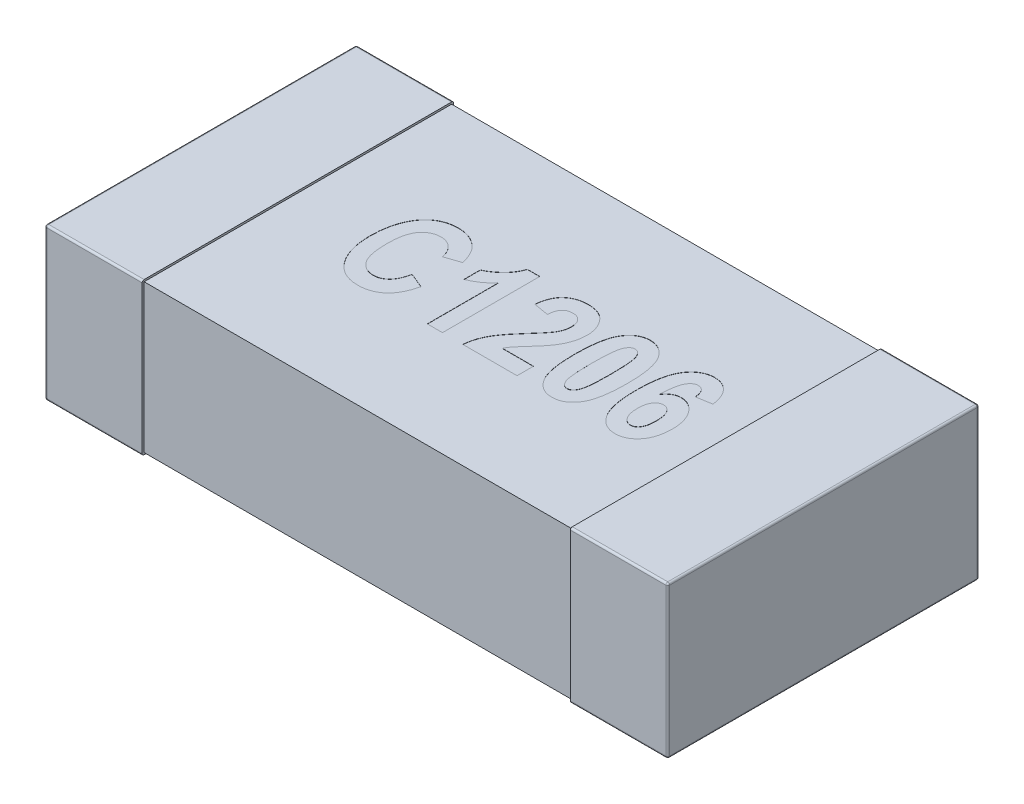
from build123d import *

# Parameters (mm, degrees)
SKETCH1_W            = 0.5
SKETCH1_H            = 1.6
THICKNESS_DEPTH      = 0.78
FILLET1_R            = 0.01
SKETCH2_W            = 1.58
SKETCH2_H            = 0.76
BOSS_EXTRUDE2_DEPTH  = 1.1
FILLET1_OF_MIRROR3_R = 0.01
CUT_EXTRUDE1_DEPTH   = 0.001


with BuildPart() as part:
    # Sketch1 → THICKNESS (new body)
    with BuildSketch(Plane(origin=(0, 0, 0), x_dir=(1, 0, 0), z_dir=(0, 1, 0))):
        with Locations((-1.35, 0)):
            Rectangle(SKETCH1_W, SKETCH1_H)
    thickness = extrude(amount=THICKNESS_DEPTH)

    # Fillet1
    fillet1_edges = [part.edges().sort_by_distance(p)[0] for p in [
        (-1.35, 0.78, -0.8),
        (-1.6, 0.78, 0),
        (-1.35, 0, -0.8),
        (-1.35, 0, 0.8),
        (-1.6, 0, 0),
        (-1.35, 0.78, 0.8),
        (-1.6, 0.39, -0.8),
        (-1.6, 0.39, 0.8),
    ]]
    fillet(fillet1_edges, radius=FILLET1_R)

    # Sketch2 → Boss-Extrude2 (add)
    with BuildSketch(Plane(origin=(0, 0, 0), x_dir=(0, 0, -1), z_dir=(1, 0, 0))):
        with Locations((0, 0.39)):
            Rectangle(SKETCH2_W, SKETCH2_H)
    boss_extrude2 = extrude(amount=-BOSS_EXTRUDE2_DEPTH)

    # Mirror3: THICKNESS, Boss-Extrude2 across plane
    add(thickness.mirror(Plane(origin=(0, 0, 0), x_dir=(0, 0, 1), z_dir=(1, 0, 0))))
    add(boss_extrude2.mirror(Plane(origin=(0, 0, 0), x_dir=(0, 0, 1), z_dir=(1, 0, 0))))

    # Fillet1 of Mirror3
    fillet1_of_mirror3_edges = [part.edges().sort_by_distance(p)[0] for p in [
        (1.35, 0.78, -0.8),
        (1.6, 0.78, 0),
        (1.35, 0, -0.8),
        (1.35, 0, 0.8),
        (1.6, 0, 0),
        (1.35, 0.78, 0.8),
        (1.6, 0.39, -0.8),
        (1.6, 0.39, 0.8),
    ]]
    fillet(fillet1_of_mirror3_edges, radius=FILLET1_OF_MIRROR3_R)

    # Sketch3 → Cut-Extrude1 (cut)
    with BuildSketch(Plane(origin=(0, 0.77, 0), x_dir=(1, 0, 0), z_dir=(0, 1, 0))):
        with BuildLine():
            Line((-0.444805195, -0.068181818), (-0.366883117, -0.100649351))
            add(Edge.make_bspline(
                [(-0.366883117, -0.100649351), (-0.36849243, -0.107199419), (-0.371628256, -0.119962551), (-0.377560807, -0.138204654), (-0.384088901, -0.155130547), (-0.391557408, -0.17064549), (-0.399710269, -0.1848856), (-0.40876644, -0.19771075), (-0.418555537, -0.209186605), (-0.429133236, -0.219286352), (-0.440482385, -0.227976376), (-0.452284327, -0.23572007), (-0.464843824, -0.24206825), (-0.477985009, -0.247428311), (-0.491811195, -0.251412625), (-0.506217336, -0.254410987), (-0.521265264, -0.256126789), (-0.531516362, -0.256369892), (-0.536728896, -0.256493506)],
                knots=[0, 0, 0, 0, 2.0228e-05, 3.9416e-05, 5.7504e-05, 7.4612e-05, 9.1023e-05, 0.000106675, 0.000121641, 0.00013621, 0.000150457, 0.000164472, 0.000178493, 0.000192605, 0.000206988, 0.000221594, 0.000236709, 0.000252346, 0.000252346, 0.000252346, 0.000252346], degree=3))
            add(Edge.make_bspline(
                [(-0.536728896, -0.256493506), (-0.543269039, -0.256346468), (-0.556081026, -0.256058423), (-0.574776176, -0.252959131), (-0.592566222, -0.248250296), (-0.609419096, -0.24148838), (-0.625354781, -0.232845212), (-0.640204933, -0.222139378), (-0.654316065, -0.209769439), (-0.662520716, -0.200124533), (-0.666700487, -0.195211039)],
                knots=[0, 0, 0, 0, 1.9603e-05, 3.8402e-05, 5.6689e-05, 7.472e-05, 9.2745e-05, 0.000110932, 0.000129545, 0.000148874, 0.000148874, 0.000148874, 0.000148874], degree=3))
            add(Edge.make_bspline(
                [(-0.666700487, -0.195211039), (-0.671294895, -0.189144714), (-0.680550756, -0.176923542), (-0.692170974, -0.156770852), (-0.702054193, -0.135120172), (-0.710143121, -0.111951881), (-0.716448013, -0.08724031), (-0.720855952, -0.060973678), (-0.723503053, -0.033164691), (-0.723849024, -0.014109002), (-0.724025974, -0.004362825)],
                knots=[0, 0, 0, 0, 2.2811e-05, 4.5956e-05, 6.961e-05, 9.4126e-05, 0.000119472, 0.000146027, 0.000173952, 0.000203187, 0.000203187, 0.000203187, 0.000203187], degree=3))
            add(Edge.make_bspline(
                [(-0.724025974, -0.004362825), (-0.723864318, 0.005925643), (-0.723549438, 0.025965852), (-0.720714427, 0.055142491), (-0.716392573, 0.082649117), (-0.709948869, 0.108383494), (-0.70187671, 0.132493389), (-0.691903581, 0.154828456), (-0.680323777, 0.175622287), (-0.67087598, 0.188041064), (-0.666193182, 0.194196429)],
                knots=[0, 0, 0, 0, 3.0858e-05, 6.0106e-05, 8.7861e-05, 0.000114315, 0.000139598, 0.000164034, 0.000187618, 0.000210795, 0.000210795, 0.000210795, 0.000210795], degree=3))
            add(Edge.make_bspline(
                [(-0.666193182, 0.194196429), (-0.661941432, 0.19917207), (-0.653562146, 0.208977992), (-0.639239952, 0.221675972), (-0.62385342, 0.232469708), (-0.607408116, 0.241307035), (-0.589830453, 0.24818042), (-0.571206463, 0.253030388), (-0.551461576, 0.255892063), (-0.53795592, 0.256289961), (-0.531047078, 0.256493506)],
                knots=[0, 0, 0, 0, 1.9616e-05, 3.8658e-05, 5.7235e-05, 7.5892e-05, 9.4527e-05, 0.000113722, 0.000133509, 0.000154232, 0.000154232, 0.000154232, 0.000154232], degree=3))
            add(Edge.make_bspline(
                [(-0.531047078, 0.256493506), (-0.525393125, 0.256358172), (-0.514280545, 0.256092177), (-0.497985961, 0.253965699), (-0.482461365, 0.250226584), (-0.467555212, 0.245322032), (-0.453398282, 0.238759793), (-0.439949639, 0.230796898), (-0.427156396, 0.221459527), (-0.41940221, 0.214200592), (-0.415482955, 0.210531656)],
                knots=[0, 0, 0, 0, 1.6959e-05, 3.3332e-05, 4.9181e-05, 6.4806e-05, 8.0332e-05, 9.5888e-05, 0.000111636, 0.000127729, 0.000127729, 0.000127729, 0.000127729], degree=3))
            add(Edge.make_bspline(
                [(-0.415482955, 0.210531656), (-0.412757934, 0.207703941), (-0.40720511, 0.201941852), (-0.399728219, 0.192235974), (-0.392805915, 0.18154683), (-0.386562308, 0.169828804), (-0.380757826, 0.157196426), (-0.37547971, 0.143584945), (-0.370836439, 0.128963394), (-0.368221249, 0.118824301), (-0.366883117, 0.113636364)],
                knots=[0, 0, 0, 0, 1.1774e-05, 2.3992e-05, 3.6684e-05, 4.994e-05, 6.3787e-05, 7.837e-05, 9.3708e-05, 0.000109779, 0.000109779, 0.000109779, 0.000109779], degree=3))
            Line((-0.366883117, 0.113636364), (-0.444805195, 0.087662338))
            add(Edge.make_bspline(
                [(-0.444805195, 0.087662338), (-0.445537424, 0.090987951), (-0.446962221, 0.097459042), (-0.449822852, 0.106797707), (-0.453305555, 0.115471471), (-0.457094781, 0.123688559), (-0.461657641, 0.131164757), (-0.466430536, 0.13825728), (-0.472027202, 0.14454098), (-0.477939924, 0.150346042), (-0.484377262, 0.155362577), (-0.490966456, 0.159899251), (-0.497903955, 0.163671163), (-0.505160821, 0.166704728), (-0.512651103, 0.169159799), (-0.520430615, 0.170886266), (-0.528481552, 0.171931755), (-0.533952436, 0.172028715), (-0.536728896, 0.172077922)],
                knots=[0, 0, 0, 0, 1.0213e-05, 1.9873e-05, 2.9256e-05, 3.8242e-05, 4.6977e-05, 5.5506e-05, 6.3848e-05, 7.2171e-05, 8.0332e-05, 8.8296e-05, 9.615e-05, 0.000103971, 0.000111864, 0.000119765, 0.000127845, 0.00013617, 0.00013617, 0.00013617, 0.00013617], degree=3))
            add(Edge.make_bspline(
                [(-0.536728896, 0.172077922), (-0.540658276, 0.17196142), (-0.548391697, 0.171732133), (-0.559721825, 0.169907877), (-0.570441665, 0.166681277), (-0.580712608, 0.162445387), (-0.590362065, 0.156801919), (-0.599497455, 0.1499676), (-0.607873139, 0.141735893), (-0.615900349, 0.132476634), (-0.623174359, 0.12174862), (-0.62935049, 0.109349888), (-0.634444677, 0.095324702), (-0.638832718, 0.079773649), (-0.64211578, 0.062594558), (-0.644394124, 0.043814032), (-0.645816067, 0.023459305), (-0.646005747, 0.009336857), (-0.646103896, 0.002029221)],
                knots=[0, 0, 0, 0, 1.1785e-05, 2.3195e-05, 3.4303e-05, 4.5307e-05, 5.6445e-05, 6.7748e-05, 7.9444e-05, 9.1604e-05, 0.000104465, 0.000118213, 0.000133045, 0.00014917, 0.000166641, 0.000185455, 0.000205898, 0.00022782, 0.00022782, 0.00022782, 0.00022782], degree=3))
            add(Edge.make_bspline(
                [(-0.646103896, 0.002029221), (-0.645992992, -0.005547936), (-0.645779425, -0.020139244), (-0.644534502, -0.041213985), (-0.642168198, -0.060576844), (-0.639139149, -0.078303959), (-0.63499418, -0.094291712), (-0.629930299, -0.108549895), (-0.624097514, -0.121217707), (-0.617139627, -0.132128944), (-0.609430151, -0.141548589), (-0.601233568, -0.149726893), (-0.592391633, -0.156558729), (-0.583140892, -0.16234867), (-0.573227375, -0.166736134), (-0.562768363, -0.169721266), (-0.551825884, -0.171785937), (-0.544314556, -0.171979291), (-0.540482955, -0.172077922)],
                knots=[0, 0, 0, 0, 2.2733e-05, 4.3777e-05, 6.3296e-05, 8.1228e-05, 9.7692e-05, 0.000112775, 0.000126572, 0.000139436, 0.000151479, 0.00016303, 0.000174091, 0.000184932, 0.000195697, 0.000206485, 0.000217511, 0.000228992, 0.000228992, 0.000228992, 0.000228992], degree=3))
            add(Edge.make_bspline(
                [(-0.540482955, -0.172077922), (-0.537672798, -0.17199089), (-0.532098235, -0.171818242), (-0.523895218, -0.170718873), (-0.515979443, -0.168753222), (-0.508349845, -0.166026103), (-0.501038939, -0.162428018), (-0.493971716, -0.158165333), (-0.487290942, -0.153041538), (-0.480823268, -0.147223721), (-0.474723084, -0.140532204), (-0.469147982, -0.132838844), (-0.463968082, -0.124281141), (-0.459214699, -0.114806021), (-0.454857518, -0.104474384), (-0.451015765, -0.093206945), (-0.447539335, -0.081059958), (-0.445734129, -0.072557215), (-0.444805195, -0.068181818)],
                knots=[0, 0, 0, 0, 8.431e-06, 1.6725e-05, 2.4772e-05, 3.2859e-05, 4.0982e-05, 4.9178e-05, 5.7579e-05, 6.6199e-05, 7.5249e-05, 8.4685e-05, 9.4656e-05, 0.000105228, 0.000116459, 0.000128267, 0.000140922, 0.000154337, 0.000154337, 0.000154337, 0.000154337], degree=3))
        make_face()
        with BuildLine():
            Line((-0.107142857, -0.25), (-0.185064935, -0.25))
            Line((-0.185064935, -0.25), (-0.185064935, 0.113636364))
            add(Edge.make_bspline(
                [(-0.185064935, 0.113636364), (-0.188844139, 0.109670682), (-0.196339186, 0.101805807), (-0.208263253, 0.090826148), (-0.220599717, 0.080703473), (-0.23342998, 0.071391888), (-0.246607234, 0.062803013), (-0.260298181, 0.055050422), (-0.274386727, 0.048117927), (-0.284099427, 0.04417926), (-0.288961039, 0.042207792)],
                knots=[0, 0, 0, 0, 1.6431e-05, 3.2586e-05, 4.8591e-05, 6.4279e-05, 8.0123e-05, 9.5753e-05, 0.000111453, 0.000127188, 0.000127188, 0.000127188, 0.000127188], degree=3))
            Line((-0.288961039, 0.042207792), (-0.288961039, 0.126623377))
            add(Edge.make_bspline(
                [(-0.288961039, 0.126623377), (-0.283357302, 0.129113926), (-0.27169064, 0.134299109), (-0.254622918, 0.144709877), (-0.237385206, 0.15774717), (-0.223082155, 0.170261945), (-0.2119263, 0.181396363), (-0.203977357, 0.190166089), (-0.196861004, 0.199428979), (-0.190265959, 0.208854386), (-0.184442966, 0.218711853), (-0.179302077, 0.22881214), (-0.174740328, 0.239221134), (-0.172360838, 0.246394344), (-0.171164773, 0.25)],
                knots=[0, 0, 0, 0, 1.8382e-05, 3.8271e-05, 5.9801e-05, 8.3166e-05, 9.5219e-05, 0.000107075, 0.000118643, 0.000130239, 0.000141566, 0.000152956, 0.000164227, 0.000175618, 0.000175618, 0.000175618, 0.000175618], degree=3))
            Line((-0.171164773, 0.25), (-0.107142857, 0.25))
            Line((-0.107142857, 0.25), (-0.107142857, -0.25))
        make_face()
        with BuildLine():
            Line((0.275974026, -0.165584416), (0.275974026, -0.25))
            Line((0.275974026, -0.25), (-0.003246753, -0.25))
            add(Edge.make_bspline(
                [(-0.003246753, -0.25), (-0.002264327, -0.241685939), (-0.000302145, -0.225080406), (0.005639436, -0.200708492), (0.013648598, -0.176899299), (0.022418661, -0.157512093), (0.031121852, -0.141858397), (0.038907445, -0.129086255), (0.048179242, -0.115495387), (0.058926165, -0.101104208), (0.070842558, -0.085699462), (0.084191971, -0.069442718), (0.098904882, -0.052319659), (0.109287121, -0.040701863), (0.114650974, -0.034699675)],
                knots=[0, 0, 0, 0, 2.5096e-05, 5.0124e-05, 7.5086e-05, 0.000100378, 0.00011382, 0.000128802, 0.000145237, 0.000163155, 0.000182679, 0.00020366, 0.000226253, 0.000250402, 0.000250402, 0.000250402, 0.000250402], degree=3))
            add(Edge.make_bspline(
                [(0.114650974, -0.034699675), (0.118856584, -0.030009116), (0.12690229, -0.021035657), (0.138219275, -0.008041245), (0.148398869, 0.003643895), (0.157116661, 0.014260993), (0.164679839, 0.023588052), (0.170947856, 0.031767255), (0.175995886, 0.038727697), (0.178694057, 0.043106948), (0.179890422, 0.045048701)],
                knots=[0, 0, 0, 0, 1.8899e-05, 3.6156e-05, 5.1695e-05, 6.5387e-05, 7.7367e-05, 8.7716e-05, 9.6303e-05, 0.000103143, 0.000103143, 0.000103143, 0.000103143], degree=3))
            add(Edge.make_bspline(
                [(0.179890422, 0.045048701), (0.182667005, 0.050022587), (0.188086956, 0.059731723), (0.193730979, 0.075117569), (0.197420143, 0.090531154), (0.197842902, 0.100899733), (0.198051948, 0.106026786)],
                knots=[0, 0, 0, 0, 1.7064e-05, 3.3309e-05, 4.9013e-05, 6.4374e-05, 6.4374e-05, 6.4374e-05, 6.4374e-05], degree=3))
            add(Edge.make_bspline(
                [(0.198051948, 0.106026786), (0.197872392, 0.111149495), (0.197532481, 0.120847112), (0.194623435, 0.134396331), (0.18976022, 0.146048473), (0.182730924, 0.155509038), (0.174173388, 0.162935219), (0.164302895, 0.168354284), (0.153131907, 0.17156447), (0.145279523, 0.171903332), (0.141233766, 0.172077922)],
                knots=[0, 0, 0, 0, 1.5354e-05, 2.9066e-05, 4.1337e-05, 5.2944e-05, 6.4092e-05, 7.508e-05, 8.6481e-05, 9.8597e-05, 9.8597e-05, 9.8597e-05, 9.8597e-05], degree=3))
            add(Edge.make_bspline(
                [(0.141233766, 0.172077922), (0.13684657, 0.17188621), (0.128437739, 0.171518759), (0.116611044, 0.16809776), (0.106346081, 0.162458457), (0.097934255, 0.154273831), (0.091030454, 0.144048519), (0.086046051, 0.131479307), (0.082628638, 0.116804978), (0.081674834, 0.106249263), (0.081168831, 0.100649351)],
                knots=[0, 0, 0, 0, 1.3136e-05, 2.5177e-05, 3.6579e-05, 4.7919e-05, 6.0047e-05, 7.3331e-05, 8.8244e-05, 0.000105096, 0.000105096, 0.000105096, 0.000105096], degree=3))
            Line((0.081168831, 0.100649351), (0.003246753, 0.113636364))
            add(Edge.make_bspline(
                [(0.003246753, 0.113636364), (0.003899244, 0.119332466), (0.005164998, 0.130382229), (0.008516652, 0.146253679), (0.012485975, 0.16100631), (0.017456055, 0.174563774), (0.023349957, 0.186943755), (0.030187652, 0.198132606), (0.037771992, 0.2083186), (0.046485738, 0.21715758), (0.055981182, 0.224890528), (0.066194237, 0.231658918), (0.077200094, 0.237318568), (0.088902756, 0.242038085), (0.10140814, 0.245532196), (0.114589028, 0.248207098), (0.12854981, 0.249715818), (0.138085002, 0.249903879), (0.142958604, 0.25)],
                knots=[0, 0, 0, 0, 1.7191e-05, 3.3348e-05, 4.861e-05, 6.2991e-05, 7.6605e-05, 8.9673e-05, 0.000102275, 0.000114616, 0.000126801, 0.000138958, 0.000151301, 0.000163868, 0.000176746, 0.000190197, 0.00020418, 0.000218799, 0.000218799, 0.000218799, 0.000218799], degree=3))
            add(Edge.make_bspline(
                [(0.142958604, 0.25), (0.148310794, 0.249913806), (0.15868481, 0.249746739), (0.173712777, 0.247578705), (0.187783279, 0.244489713), (0.20075787, 0.239684873), (0.212863389, 0.23390512), (0.223749129, 0.226422834), (0.233861603, 0.217942554), (0.242531698, 0.207874864), (0.250424044, 0.197233269), (0.257200522, 0.186017626), (0.263067858, 0.174525665), (0.267743304, 0.162551878), (0.271383227, 0.150189255), (0.274006386, 0.137464131), (0.275724594, 0.124370547), (0.27589002, 0.115501987), (0.275974026, 0.110998377)],
                knots=[0, 0, 0, 0, 1.6042e-05, 3.1095e-05, 4.5468e-05, 5.9172e-05, 7.2513e-05, 8.5598e-05, 9.8694e-05, 0.00011199, 0.000125343, 0.000138411, 0.000151252, 0.000164008, 0.000176914, 0.000189868, 0.000202956, 0.00021646, 0.00021646, 0.00021646, 0.00021646], degree=3))
            add(Edge.make_bspline(
                [(0.275974026, 0.110998377), (0.275888769, 0.105886592), (0.275719507, 0.09573815), (0.273981187, 0.080625849), (0.271413763, 0.065724148), (0.267605232, 0.051013003), (0.262680397, 0.036417581), (0.256683416, 0.021811521), (0.249577542, 0.007146885), (0.242580242, -0.005003638), (0.236310531, -0.015098102), (0.230727545, -0.023166685), (0.224364899, -0.031707118), (0.217400977, -0.040863101), (0.209562723, -0.050458392), (0.20104128, -0.060607178), (0.191806854, -0.071261769), (0.185346039, -0.078472551), (0.182021104, -0.082183442)],
                knots=[0, 0, 0, 0, 1.5329e-05, 3.0433e-05, 4.5579e-05, 6.0664e-05, 7.5968e-05, 9.1758e-05, 0.000108003, 0.000124816, 0.000133796, 0.000143646, 0.000154239, 0.000165746, 0.000178153, 0.000191404, 0.000205501, 0.000220449, 0.000220449, 0.000220449, 0.000220449], degree=3))
            add(Edge.make_bspline(
                [(0.182021104, -0.082183442), (0.178942311, -0.085598203), (0.17307254, -0.092108502), (0.164700254, -0.101431184), (0.157370753, -0.109983543), (0.150727793, -0.117454332), (0.145061671, -0.124062865), (0.140227935, -0.129727022), (0.136441745, -0.134613568), (0.130707011, -0.141752834), (0.123819825, -0.151802082), (0.118931214, -0.161106822), (0.116578734, -0.165584416)],
                knots=[0, 0, 0, 0, 1.3793e-05, 2.6297e-05, 3.7589e-05, 4.7582e-05, 5.6287e-05, 6.3705e-05, 6.9916e-05, 7.4829e-05, 9.1179e-05, 0.000106346, 0.000106346, 0.000106346, 0.000106346], degree=3))
            Line((0.116578734, -0.165584416), (0.275974026, -0.165584416))
        make_face()
        with BuildLine():
            add(Edge.make_bspline(
                [(0.460836039, 0.25), (0.465684472, 0.249821792), (0.475251481, 0.249470149), (0.489210012, 0.246766729), (0.502498486, 0.242374653), (0.515025097, 0.236143966), (0.526797496, 0.228118917), (0.53784526, 0.218348457), (0.548177049, 0.206836773), (0.557859306, 0.193480545), (0.566560103, 0.177859767), (0.57399117, 0.159693329), (0.580232042, 0.138918508), (0.585317445, 0.115537824), (0.589351543, 0.089518058), (0.592083486, 0.060856824), (0.59382284, 0.029580494), (0.594041935, 0.007848831), (0.594155844, -0.003449675)],
                knots=[0, 0, 0, 0, 1.4538e-05, 2.8686e-05, 4.2482e-05, 5.6412e-05, 7.0511e-05, 8.5105e-05, 0.00010055, 0.000116827, 0.000134497, 0.000154055, 0.000175591, 0.000199494, 0.000225783, 0.000254536, 0.000285833, 0.000319727, 0.000319727, 0.000319727, 0.000319727], degree=3))
            add(Edge.make_bspline(
                [(0.594155844, -0.003449675), (0.594041685, -0.014714314), (0.593822137, -0.036378293), (0.592086664, -0.067554004), (0.589339378, -0.096144843), (0.585338052, -0.122104164), (0.580191615, -0.145467919), (0.574038726, -0.166238321), (0.566529935, -0.184373786), (0.557868688, -0.199980884), (0.548168467, -0.213292841), (0.537949181, -0.224873693), (0.526895871, -0.234612008), (0.515145958, -0.242606903), (0.502680591, -0.248896043), (0.489472282, -0.253224787), (0.475594295, -0.255983406), (0.46609148, -0.256321146), (0.461241883, -0.256493506)],
                knots=[0, 0, 0, 0, 3.3792e-05, 6.4988e-05, 9.364e-05, 0.000119929, 0.000143733, 0.000165366, 0.000184831, 0.0002025, 0.000218777, 0.000234155, 0.000248748, 0.000262847, 0.000276686, 0.000290483, 0.000304432, 0.000318969, 0.000318969, 0.000318969, 0.000318969], degree=3))
            add(Edge.make_bspline(
                [(0.461241883, -0.256493506), (0.456395515, -0.256303915), (0.446838771, -0.255930052), (0.432856549, -0.253392684), (0.419577696, -0.248965764), (0.407082447, -0.242729557), (0.395279592, -0.234825893), (0.38423747, -0.225147516), (0.37389174, -0.213746876), (0.366026522, -0.202897105), (0.360112424, -0.193304928), (0.355986775, -0.1852818), (0.352141496, -0.176592461), (0.348440242, -0.167286007), (0.345268669, -0.157180364), (0.342209045, -0.146467181), (0.33946248, -0.135060526), (0.337092592, -0.122995749), (0.334775132, -0.110298311), (0.333052531, -0.096875208), (0.331348053, -0.082818126), (0.330217034, -0.068020124), (0.32915809, -0.052600797), (0.328505714, -0.036461881), (0.327919876, -0.019687621), (0.327921335, -0.008252747), (0.327922078, -0.002435065)],
                knots=[0, 0, 0, 0, 1.4538e-05, 2.8667e-05, 4.2464e-05, 5.6394e-05, 7.0436e-05, 8.4963e-05, 0.000100333, 0.000116528, 0.000125089, 0.000134119, 0.000143566, 0.00015359, 0.000164146, 0.000175324, 0.000187013, 0.00019933, 0.000212207, 0.000225724, 0.00023992, 0.000254682, 0.000270239, 0.000286286, 0.000303136, 0.000320587, 0.000320587, 0.000320587, 0.000320587], degree=3))
            add(Edge.make_bspline(
                [(0.327922078, -0.002435065), (0.328035906, 0.008795816), (0.328254793, 0.030392322), (0.329994049, 0.061465965), (0.332724634, 0.08992472), (0.336766464, 0.115774936), (0.341864953, 0.139048335), (0.348060315, 0.1597722), (0.355545975, 0.177880872), (0.364209707, 0.193487238), (0.37390934, 0.206799368), (0.384128769, 0.218380178), (0.395182044, 0.228118504), (0.406931966, 0.236113396), (0.41939733, 0.242402536), (0.43260564, 0.24673128), (0.446483627, 0.249489899), (0.455986442, 0.24982764), (0.460836039, 0.25)],
                knots=[0, 0, 0, 0, 3.3691e-05, 6.4786e-05, 9.3336e-05, 0.000119425, 0.000143229, 0.000164765, 0.00018423, 0.000201899, 0.000218176, 0.000233553, 0.000248147, 0.000262246, 0.000276085, 0.000289882, 0.000303831, 0.000318368, 0.000318368, 0.000318368, 0.000318368], degree=3))
        make_face()
        with BuildLine():
            add(Edge.make_bspline(
                [(0.461038961, 0.172077922), (0.459236992, 0.171974276), (0.455644856, 0.171767663), (0.450420958, 0.170285708), (0.445450316, 0.167927863), (0.440827201, 0.164496036), (0.436583703, 0.160035759), (0.43250874, 0.154745837), (0.428761931, 0.148473406), (0.425164374, 0.14106447), (0.422107219, 0.131760859), (0.41941497, 0.120158002), (0.417297064, 0.105935229), (0.415524895, 0.089107522), (0.413985354, 0.06969102), (0.413052791, 0.04762668), (0.41243539, 0.022967619), (0.41237132, 0.005648455), (0.412337662, -0.003449675)],
                knots=[0, 0, 0, 0, 5.401e-06, 1.0767e-05, 1.6168e-05, 2.1829e-05, 2.7928e-05, 3.4584e-05, 4.1823e-05, 4.981e-05, 5.9243e-05, 7.113e-05, 8.5509e-05, 0.000102349, 0.000121889, 0.000143929, 0.000168592, 0.000195886, 0.000195886, 0.000195886, 0.000195886], degree=3))
            add(Edge.make_bspline(
                [(0.412337662, -0.003449675), (0.412370712, -0.012547833), (0.412433504, -0.029833238), (0.413056759, -0.054458165), (0.413977672, -0.076455775), (0.415540624, -0.095870021), (0.417278481, -0.112667766), (0.419424751, -0.12688743), (0.422113029, -0.138454336), (0.425136893, -0.147740203), (0.428787628, -0.155090724), (0.432512427, -0.161335741), (0.436548286, -0.166632379), (0.440862727, -0.170988044), (0.445446336, -0.174425311), (0.450421991, -0.176778192), (0.455644596, -0.178261427), (0.459236905, -0.178467869), (0.461038961, -0.178571429)],
                knots=[0, 0, 0, 0, 2.7294e-05, 5.1855e-05, 7.3895e-05, 9.3334e-05, 0.000110275, 0.000124554, 0.00013644, 0.000145874, 0.000153769, 0.000161008, 0.000167664, 0.000173691, 0.000179353, 0.000184753, 0.000190119, 0.00019552, 0.00019552, 0.00019552, 0.00019552], degree=3))
            add(Edge.make_bspline(
                [(0.461038961, -0.178571429), (0.462874777, -0.178470018), (0.466500903, -0.178269711), (0.471762069, -0.176783908), (0.47673982, -0.174390863), (0.481452743, -0.171031061), (0.485653386, -0.166527704), (0.489821594, -0.161364073), (0.493389479, -0.15502947), (0.497020851, -0.147665867), (0.500097647, -0.138367407), (0.502594823, -0.126726323), (0.504933927, -0.112545267), (0.506660342, -0.095737378), (0.50806137, -0.076349336), (0.509033466, -0.054357467), (0.50963995, -0.029765364), (0.509705709, -0.012513932), (0.50974026, -0.003449675)],
                knots=[0, 0, 0, 0, 5.502e-06, 1.0868e-05, 1.6269e-05, 2.2013e-05, 2.8111e-05, 3.4687e-05, 4.1874e-05, 4.9861e-05, 5.9294e-05, 7.1158e-05, 8.5553e-05, 0.000102393, 0.000121824, 0.000143865, 0.000168426, 0.000195618, 0.000195618, 0.000195618, 0.000195618], degree=3))
            add(Edge.make_bspline(
                [(0.50974026, -0.003449675), (0.509705436, 0.005648387), (0.509639146, 0.022967423), (0.509036641, 0.047627348), (0.508056297, 0.069686364), (0.506665777, 0.089108963), (0.504933596, 0.105950344), (0.502594624, 0.120131141), (0.500098422, 0.13177305), (0.497018697, 0.141069233), (0.493395934, 0.148439491), (0.48978757, 0.154776307), (0.485687405, 0.160026831), (0.481448936, 0.164534599), (0.476740748, 0.167898077), (0.47176183, 0.170290216), (0.466500964, 0.171776252), (0.462874798, 0.171976528), (0.461038961, 0.172077922)],
                knots=[0, 0, 0, 0, 2.7294e-05, 5.1956e-05, 7.3997e-05, 9.3529e-05, 0.000110369, 0.000124764, 0.000136628, 0.000146061, 0.000154048, 0.000161235, 0.000167891, 0.00017399, 0.000179734, 0.000185134, 0.0001905, 0.000196002, 0.000196002, 0.000196002, 0.000196002], degree=3))
        make_face(mode=Mode.SUBTRACT)
        with BuildLine():
            Line((0.905844156, 0.126623377), (0.827922078, 0.113636364))
            add(Edge.make_bspline(
                [(0.827922078, 0.113636364), (0.827409329, 0.118216652), (0.826443658, 0.12684281), (0.82363467, 0.138816516), (0.819807622, 0.148969751), (0.815077648, 0.157446183), (0.809079145, 0.164038938), (0.802001764, 0.168723313), (0.793876393, 0.171627802), (0.788106754, 0.171923899), (0.785105519, 0.172077922)],
                knots=[0, 0, 0, 0, 1.3818e-05, 2.6025e-05, 3.6784e-05, 4.6285e-05, 5.4974e-05, 6.3247e-05, 7.1526e-05, 8.0501e-05, 8.0501e-05, 8.0501e-05, 8.0501e-05], degree=3))
            add(Edge.make_bspline(
                [(0.785105519, 0.172077922), (0.783101548, 0.172013132), (0.779149395, 0.171885355), (0.773383489, 0.170462965), (0.767827724, 0.168337407), (0.762519214, 0.165258755), (0.757539961, 0.161249086), (0.752859472, 0.156404372), (0.748361392, 0.150797684), (0.744123237, 0.144163817), (0.740201357, 0.136200284), (0.736831783, 0.126539063), (0.733712906, 0.115185419), (0.731005757, 0.102032157), (0.728737063, 0.087089141), (0.726709773, 0.070377024), (0.725099184, 0.05190014), (0.724393961, 0.038997326), (0.724025974, 0.03226461)],
                knots=[0, 0, 0, 0, 6e-06, 1.1833e-05, 1.7711e-05, 2.3803e-05, 3.0157e-05, 3.6829e-05, 4.3975e-05, 5.1687e-05, 6.0399e-05, 7.0541e-05, 8.2332e-05, 9.5704e-05, 0.000110801, 0.000127664, 0.000146201, 0.000166429, 0.000166429, 0.000166429, 0.000166429], degree=3))
            add(Edge.make_bspline(
                [(0.724025974, 0.03226461), (0.726431058, 0.035628327), (0.731093422, 0.042149046), (0.738922071, 0.050825783), (0.747231698, 0.05809695), (0.755871864, 0.064160845), (0.765006667, 0.068896642), (0.774624661, 0.072296591), (0.784758578, 0.07422322), (0.791658899, 0.074523431), (0.795150162, 0.074675325)],
                knots=[0, 0, 0, 0, 1.2399e-05, 2.4035e-05, 3.4964e-05, 4.5462e-05, 5.5627e-05, 6.5735e-05, 7.5963e-05, 8.6437e-05, 8.6437e-05, 8.6437e-05, 8.6437e-05], degree=3))
            add(Edge.make_bspline(
                [(0.795150162, 0.074675325), (0.799012903, 0.074527693), (0.806690113, 0.074234274), (0.818014952, 0.072221268), (0.82887432, 0.06855079), (0.839418485, 0.063662961), (0.84955478, 0.05734273), (0.859318229, 0.049616594), (0.868600208, 0.040443432), (0.87747545, 0.030037905), (0.885728825, 0.01853989), (0.892764553, 0.005891233), (0.898909943, -0.007553565), (0.903921457, -0.021943371), (0.907582167, -0.037293727), (0.910317551, -0.0535284), (0.91211451, -0.070644282), (0.912262254, -0.082381738), (0.912337662, -0.088372565)],
                knots=[0, 0, 0, 0, 1.1588e-05, 2.3032e-05, 3.4358e-05, 4.5887e-05, 5.7825e-05, 7.0106e-05, 8.3164e-05, 9.6909e-05, 0.000111098, 0.000125546, 0.000140257, 0.000155402, 0.000171176, 0.00018754, 0.000204773, 0.000222739, 0.000222739, 0.000222739, 0.000222739], degree=3))
            add(Edge.make_bspline(
                [(0.912337662, -0.088372565), (0.912220766, -0.094768861), (0.911993333, -0.107213546), (0.910234656, -0.125315501), (0.907456051, -0.142359904), (0.903379903, -0.158338581), (0.898208408, -0.173315309), (0.891952456, -0.187295338), (0.88440705, -0.200138136), (0.875774556, -0.211783591), (0.866349159, -0.222237288), (0.856309392, -0.231408819), (0.845705258, -0.239184459), (0.834555621, -0.245553816), (0.822799266, -0.250471668), (0.810450543, -0.253867968), (0.797598463, -0.256108179), (0.788835258, -0.256363929), (0.784395292, -0.256493506)],
                knots=[0, 0, 0, 0, 1.9186e-05, 3.7328e-05, 5.4509e-05, 7.0947e-05, 8.6734e-05, 0.000101991, 0.000116817, 0.000131326, 0.000145406, 0.000158981, 0.00017205, 0.000184773, 0.000197417, 0.000210169, 0.00022313, 0.00023644, 0.00023644, 0.00023644, 0.00023644], degree=3))
            add(Edge.make_bspline(
                [(0.784395292, -0.256493506), (0.779511013, -0.256325923), (0.769866508, -0.255995012), (0.755789635, -0.253127252), (0.742294747, -0.248694819), (0.729567445, -0.242163007), (0.71734688, -0.233994166), (0.705902315, -0.223858199), (0.695098625, -0.211956386), (0.684866016, -0.198286984), (0.675549339, -0.182472141), (0.667728808, -0.164186593), (0.660922595, -0.14366439), (0.655572315, -0.120686087), (0.651192355, -0.095422136), (0.648262205, -0.067731302), (0.646417591, -0.037701246), (0.646210979, -0.016879309), (0.646103896, -0.006087662)],
                knots=[0, 0, 0, 0, 1.4639e-05, 2.8906e-05, 4.2927e-05, 5.7129e-05, 7.1678e-05, 8.6921e-05, 0.000102864, 0.000119828, 0.000138065, 0.000157783, 0.000179376, 0.000202853, 0.000228491, 0.000256255, 0.000286343, 0.000318715, 0.000318715, 0.000318715, 0.000318715], degree=3))
            add(Edge.make_bspline(
                [(0.646103896, -0.006087662), (0.646205373, 0.004873038), (0.646401294, 0.02603488), (0.64832458, 0.056581141), (0.651537505, 0.084759896), (0.655931699, 0.110524164), (0.661539549, 0.133969917), (0.668612608, 0.154987565), (0.676875905, 0.173696696), (0.686463837, 0.190037295), (0.697248857, 0.20403478), (0.708515717, 0.216386255), (0.720638339, 0.226838936), (0.73358431, 0.235302049), (0.747231104, 0.241887892), (0.761591218, 0.246571658), (0.776698748, 0.249523425), (0.787053443, 0.249839545), (0.792309253, 0.25)],
                knots=[0, 0, 0, 0, 3.2879e-05, 6.348e-05, 9.1771e-05, 0.000117926, 0.000141845, 0.000164016, 0.000184362, 0.000203103, 0.000220697, 0.000237282, 0.000253184, 0.000268578, 0.000283553, 0.000298505, 0.000313787, 0.00032954, 0.00032954, 0.00032954, 0.00032954], degree=3))
            add(Edge.make_bspline(
                [(0.792309253, 0.25), (0.795932834, 0.249898306), (0.803072772, 0.249697927), (0.813535324, 0.248242396), (0.82357654, 0.245929906), (0.833173268, 0.242561872), (0.84232607, 0.238154792), (0.851077929, 0.232882107), (0.859373699, 0.226625738), (0.867162069, 0.219397723), (0.874527301, 0.211287307), (0.881128405, 0.20208159), (0.887003714, 0.191903934), (0.892166067, 0.180746645), (0.896782028, 0.168671598), (0.900439118, 0.155499768), (0.903640565, 0.141423663), (0.905097139, 0.13164067), (0.905844156, 0.126623377)],
                knots=[0, 0, 0, 0, 1.0868e-05, 2.1415e-05, 3.1628e-05, 4.1736e-05, 5.1856e-05, 6.2053e-05, 7.2341e-05, 8.2968e-05, 9.3888e-05, 0.000105152, 0.000116881, 0.000129091, 0.000142, 0.000155616, 0.000170065, 0.000185278, 0.000185278, 0.000185278, 0.000185278], degree=3))
        make_face()
        with BuildLine():
            add(Edge.make_bspline(
                [(0.730519481, -0.085227273), (0.730593109, -0.088880842), (0.730736413, -0.095991786), (0.731407746, -0.106362598), (0.732671023, -0.116072283), (0.734691166, -0.125089158), (0.736925553, -0.133466844), (0.739786041, -0.141191686), (0.743254506, -0.148208669), (0.747167552, -0.154559088), (0.751455793, -0.160169031), (0.755929117, -0.165028626), (0.760467331, -0.169284227), (0.765276648, -0.172576617), (0.770099644, -0.17537486), (0.775206228, -0.177133129), (0.780418202, -0.178320259), (0.783949141, -0.178487715), (0.785714286, -0.178571429)],
                knots=[0, 0, 0, 0, 1.0962e-05, 2.1335e-05, 3.1165e-05, 4.0299e-05, 4.9037e-05, 5.716e-05, 6.4965e-05, 7.2482e-05, 7.9504e-05, 8.611e-05, 9.2287e-05, 9.8114e-05, 0.000103563, 0.000108955, 0.000114249, 0.00011954, 0.00011954, 0.00011954, 0.00011954], degree=3))
            add(Edge.make_bspline(
                [(0.785714286, -0.178571429), (0.78910135, -0.178358066), (0.795793428, -0.17793651), (0.805240351, -0.173883771), (0.81366044, -0.167434056), (0.819723608, -0.160224638), (0.823952372, -0.153210577), (0.826807149, -0.146992003), (0.829062599, -0.139912915), (0.831123707, -0.132141304), (0.832634253, -0.123554472), (0.833558911, -0.114191838), (0.834349997, -0.104044384), (0.834393185, -0.096998565), (0.834415584, -0.093344156)],
                knots=[0, 0, 0, 0, 1.0118e-05, 1.9991e-05, 3.0279e-05, 4.1725e-05, 4.8006e-05, 5.4816e-05, 6.2196e-05, 7.0268e-05, 7.8925e-05, 8.8314e-05, 9.8485e-05, 0.000109445, 0.000109445, 0.000109445, 0.000109445], degree=3))
            add(Edge.make_bspline(
                [(0.834415584, -0.093344156), (0.834386373, -0.089555237), (0.83432998, -0.082240638), (0.833626461, -0.071670474), (0.832397797, -0.061921659), (0.830815947, -0.052926468), (0.828703554, -0.044752762), (0.826163599, -0.03733995), (0.823160518, -0.03070759), (0.818512727, -0.023233839), (0.812060241, -0.015353363), (0.802996245, -0.008361121), (0.792883795, -0.003944124), (0.785757098, -0.003480537), (0.782163149, -0.003246753)],
                knots=[0, 0, 0, 0, 1.1365e-05, 2.1941e-05, 3.1757e-05, 4.0832e-05, 4.9322e-05, 5.7055e-05, 6.4319e-05, 7.1105e-05, 8.3421e-05, 9.4643e-05, 0.000105195, 0.000115929, 0.000115929, 0.000115929, 0.000115929], degree=3))
            add(Edge.make_bspline(
                [(0.782163149, -0.003246753), (0.778676707, -0.003503053), (0.771721012, -0.004014388), (0.761817834, -0.008118834), (0.752866771, -0.014771574), (0.746453923, -0.022257596), (0.741825041, -0.029335477), (0.738779716, -0.035471194), (0.736278744, -0.042222063), (0.734104286, -0.049565483), (0.732553677, -0.057591502), (0.731313484, -0.066221664), (0.730604691, -0.075508928), (0.730548551, -0.0819117), (0.730519481, -0.085227273)],
                knots=[0, 0, 0, 0, 1.0433e-05, 2.0814e-05, 3.163e-05, 4.3638e-05, 5.0167e-05, 5.6973e-05, 6.4134e-05, 7.1743e-05, 7.9921e-05, 8.8631e-05, 9.7891e-05, 0.000107837, 0.000107837, 0.000107837, 0.000107837], degree=3))
        make_face(mode=Mode.SUBTRACT)
    extrude(amount=-CUT_EXTRUDE1_DEPTH, mode=Mode.SUBTRACT)


solid = part.part
